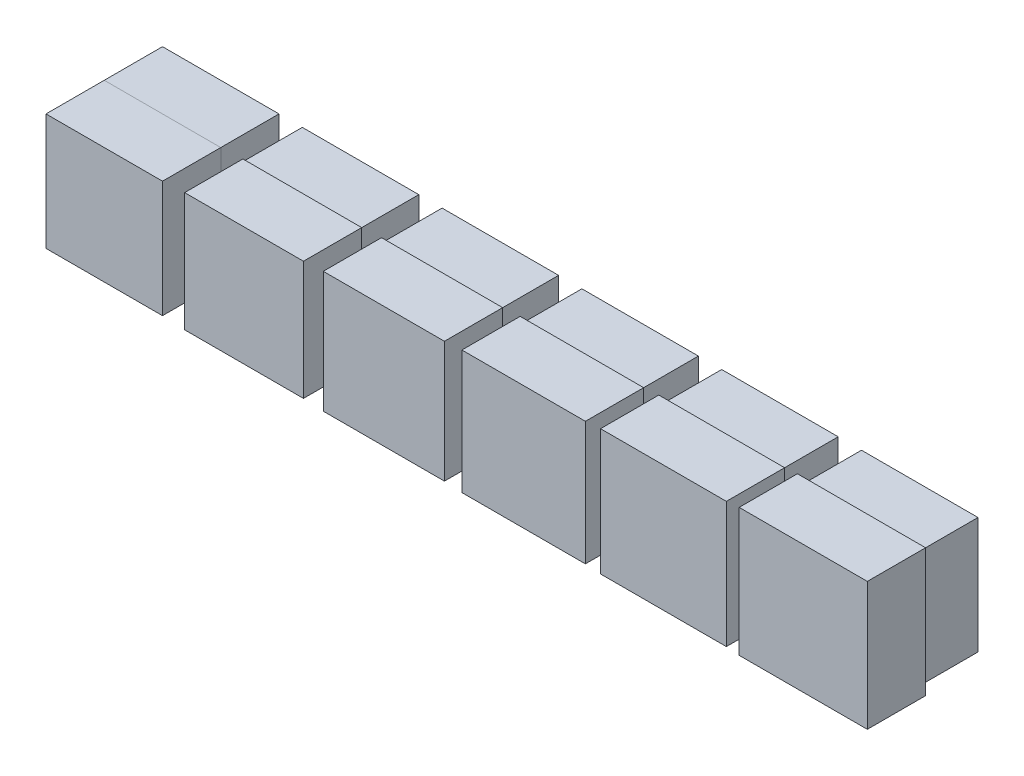
from build123d import *

# Parameters (mm, degrees)
SKETCH1_W             = 10
SKETCH1_H             = 10
BOSS_EXTRUDE1_DEPTH   = 5
BOSS_EXTRUDE1_2_DEPTH = 5
BOSS_EXTRUDE1_3_DEPTH = 5
BOSS_EXTRUDE1_4_DEPTH = 5
BOSS_EXTRUDE1_5_DEPTH = 5
BOSS_EXTRUDE1_6_DEPTH = 5
SKETCH2_W             = 10
SKETCH2_H             = 10
BOSS_EXTRUDE2_DEPTH   = 5
SKETCH2_W_2           = 10.2
SKETCH2_H_2           = 10.2
BOSS_EXTRUDE2_2_DEPTH = 5
SKETCH2_W_3           = 10.4
SKETCH2_H_3           = 10.4
BOSS_EXTRUDE2_3_DEPTH = 5
SKETCH2_W_4           = 10.6
SKETCH2_H_4           = 10.6
BOSS_EXTRUDE2_4_DEPTH = 5
SKETCH2_W_5           = 10.8
SKETCH2_H_5           = 10.8
BOSS_EXTRUDE2_5_DEPTH = 5
SKETCH2_W_6           = 11
SKETCH2_H_6           = 11
BOSS_EXTRUDE2_6_DEPTH = 5


with BuildPart() as part:
    # Sketch1 → Boss-Extrude1 (new body)
    with BuildSketch(Plane.XY):
        Rectangle(SKETCH1_W, SKETCH1_H)
    extrude(amount=BOSS_EXTRUDE1_DEPTH)


with BuildPart() as body_2:
    # Sketch1 → Boss-Extrude1 2 (new body)
    with BuildSketch(Plane.XY):
        with Locations((12, 0)):
            Rectangle(SKETCH1_W, SKETCH1_H)
    extrude(amount=BOSS_EXTRUDE1_2_DEPTH)


with BuildPart() as body_3:
    # Sketch1 → Boss-Extrude1 3 (new body)
    with BuildSketch(Plane.XY):
        with Locations((24, 0)):
            Rectangle(SKETCH1_W, SKETCH1_H)
    extrude(amount=BOSS_EXTRUDE1_3_DEPTH)


with BuildPart() as body_4:
    # Sketch1 → Boss-Extrude1 4 (new body)
    with BuildSketch(Plane.XY):
        with Locations((36, 0)):
            Rectangle(SKETCH1_W, SKETCH1_H)
    extrude(amount=BOSS_EXTRUDE1_4_DEPTH)


with BuildPart() as body_5:
    # Sketch1 → Boss-Extrude1 5 (new body)
    with BuildSketch(Plane.XY):
        with Locations((48, 0)):
            Rectangle(SKETCH1_W, SKETCH1_H)
    extrude(amount=BOSS_EXTRUDE1_5_DEPTH)


with BuildPart() as body_6:
    # Sketch1 → Boss-Extrude1 6 (new body)
    with BuildSketch(Plane.XY):
        with Locations((60, 0)):
            Rectangle(SKETCH1_W, SKETCH1_H)
    extrude(amount=BOSS_EXTRUDE1_6_DEPTH)


with BuildPart() as body_7:
    # Sketch2 → Boss-Extrude2 (new body)
    with BuildSketch(Plane.XY.offset(5)):
        Rectangle(SKETCH2_W, SKETCH2_H)
    extrude(amount=BOSS_EXTRUDE2_DEPTH)


with BuildPart() as body_8:
    # Sketch2 → Boss-Extrude2 2 (new body)
    with BuildSketch(Plane.XY.offset(5)):
        with Locations((12, 0)):
            Rectangle(SKETCH2_W_2, SKETCH2_H_2)
    extrude(amount=BOSS_EXTRUDE2_2_DEPTH)


with BuildPart() as body_9:
    # Sketch2 → Boss-Extrude2 3 (new body)
    with BuildSketch(Plane.XY.offset(5)):
        with Locations((24, 0)):
            Rectangle(SKETCH2_W_3, SKETCH2_H_3)
    extrude(amount=BOSS_EXTRUDE2_3_DEPTH)


with BuildPart() as body_10:
    # Sketch2 → Boss-Extrude2 4 (new body)
    with BuildSketch(Plane.XY.offset(5)):
        with Locations((36, 0)):
            Rectangle(SKETCH2_W_4, SKETCH2_H_4)
    extrude(amount=BOSS_EXTRUDE2_4_DEPTH)


with BuildPart() as body_11:
    # Sketch2 → Boss-Extrude2 5 (new body)
    with BuildSketch(Plane.XY.offset(5)):
        with Locations((48, 0)):
            Rectangle(SKETCH2_W_5, SKETCH2_H_5)
    extrude(amount=BOSS_EXTRUDE2_5_DEPTH)


with BuildPart() as body_12:
    # Sketch2 → Boss-Extrude2 6 (new body)
    with BuildSketch(Plane.XY.offset(5)):
        with Locations((60, 0)):
            Rectangle(SKETCH2_W_6, SKETCH2_H_6)
    extrude(amount=BOSS_EXTRUDE2_6_DEPTH)


solid = Compound([part.part, body_2.part, body_3.part, body_4.part, body_5.part, body_6.part, body_7.part, body_8.part, body_9.part, body_10.part, body_11.part, body_12.part])
